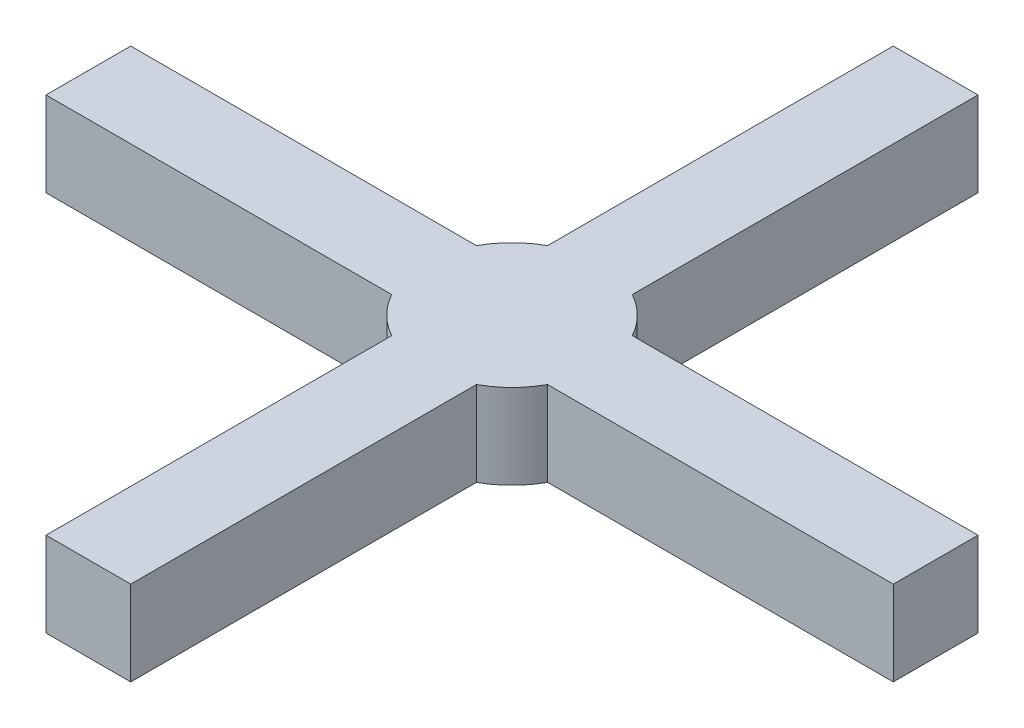
from build123d import *

# Parameters (mm, degrees)
BOSS_EXTRUDE1_START = -5105.4
BOSS_EXTRUDE1_DEPTH = 304.8


with BuildPart() as part:
    # Sketch1 → Boss-Extrude1 (new body)
    with BuildSketch(Plane(origin=(0, 0, 0), x_dir=(1, 0, 0), z_dir=(0, 1, 0)).offset(BOSS_EXTRUDE1_START)):
        with BuildLine():
            Line((-152.4, -280.359807763), (-152.4, -1524))
            Line((-152.4, -1524), (152.4, -1524))
            Line((152.4, -1524), (152.4, -280.359807763))
            ThreePointArc((152.4, -280.359807763), (225.640623347, -225.640623347), (280.359807763, -152.4))
            Line((280.359807763, -152.4), (1524, -152.4))
            Line((1524, -152.4), (1524, 152.4))
            Line((1524, 152.4), (280.359807763, 152.4))
            ThreePointArc((280.359807763, 152.4), (225.640623347, 225.640623347), (152.4, 280.359807763))
            Line((152.4, 280.359807763), (152.4, 1524))
            Line((152.4, 1524), (-152.4, 1524))
            Line((-152.4, 1524), (-152.4, 280.359807763))
            ThreePointArc((-152.4, 280.359807763), (-225.640623347, 225.640623347), (-280.359807763, 152.4))
            Line((-280.359807763, 152.4), (-1524, 152.4))
            Line((-1524, 152.4), (-1524, -152.4))
            Line((-1524, -152.4), (-280.359807763, -152.4))
            ThreePointArc((-280.359807763, -152.4), (-225.640623347, -225.640623347), (-152.4, -280.359807763))
        make_face()
    extrude(amount=-BOSS_EXTRUDE1_DEPTH)


solid = part.part
